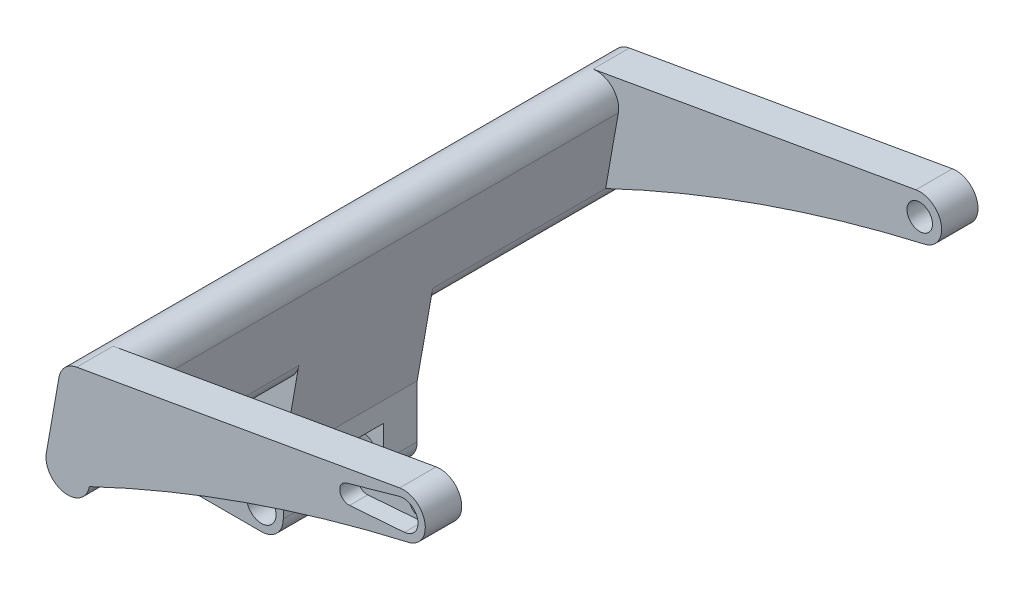
from build123d import *

# Parameters (mm, degrees)
SKETCH1_R               = 4.025
BOSS_EXTRUDE2_DEPTH     = 36.76
RIDE_SIDE_EXTRUDE_DEPTH = 57.47
LEFT_SIDE_EXTRUDE_DEPTH = 57.47
RIGHT_ARM_EXTRUDE_DEPTH = 10
SERVO_ARM_CUT_DEPTH     = 5
SKETCH18_R              = 3.5
SERVO_HOLE_DEPTH        = 152.7
SKETCH4_R               = 4.025
CUT_EXTRUDE2_DEPTH      = 18.38
SKETCH19_W              = 18.38
SKETCH19_H              = 9
CUT_EXTRUDE3_DEPTH      = 58.64


with BuildPart() as part:
    # Sketch1 → Boss-Extrude2 (new body)
    with BuildSketch(Plane.XY):
        with BuildLine():
            ThreePointArc((16.713283102, 15.01433341), (9.494630573, 8.397245558), (0, 6))
            ThreePointArc((0, 6), (-6, 0), (0, -6))
            Line((0, -6), (45.64, -6))
            ThreePointArc((45.64, -6), (49.882640687, -4.242640687), (51.64, 0))
            Line((51.64, 0), (51.64, 14.475068019))
            Line((51.64, 14.475068019), (59.363014513, 58.27445982))
            ThreePointArc((59.363014513, 58.27445982), (54.496057061, 65.225195404), (47.545321477, 60.358237952))
            Line((47.545321477, 60.358237952), (43.136706696, 35.355741095))
            ThreePointArc((43.136706696, 35.355741095), (36.080788508, 23.1345323), (22.82, 18.308))
            ThreePointArc((22.82, 18.308), (19.350841929, 17.432091905), (16.713283102, 15.01433341))
        make_face()
        Circle(SKETCH1_R, mode=Mode.SUBTRACT)
        with Locations((45.64, 0)):
            Circle(SKETCH1_R, mode=Mode.SUBTRACT)
        with Locations((22.82, 11)):
            Circle(SKETCH1_R, mode=Mode.SUBTRACT)
    extrude(amount=BOSS_EXTRUDE2_DEPTH)

    # Sketch5 → Ride-Side-Extrude (add)
    with BuildSketch(Plane.XY.offset(36.76)):
        with BuildLine():
            Line((55.89005096, 38.578304759), (59.363014513, 58.27445982))
            ThreePointArc((59.363014513, 58.27445982), (54.496057061, 65.225195404), (47.545321477, 60.358237952))
            Line((47.545321477, 60.358237952), (44.072357924, 40.662082891))
            ThreePointArc((44.072357924, 40.662082891), (48.939315376, 33.711347307), (55.89005096, 38.578304759))
        make_face()
    extrude(amount=RIDE_SIDE_EXTRUDE_DEPTH)

    # Sketch7 → Left-Side-Extrude (add)
    with BuildSketch(Plane(origin=(0, 0, 0), x_dir=(-1, 0, 0), z_dir=(0, 0, -1))):
        with BuildLine():
            Line((-44.072357924, 40.662082891), (-47.545321477, 60.358237952))
            ThreePointArc((-47.545321477, 60.358237952), (-54.496057061, 65.225195404), (-59.363014513, 58.27445982))
            Line((-59.363014513, 58.27445982), (-55.89005096, 38.578304759))
            ThreePointArc((-55.89005096, 38.578304759), (-48.939315376, 33.711347307), (-44.072357924, 40.662082891))
        make_face()
    extrude(amount=LEFT_SIDE_EXTRUDE_DEPTH)

    # Sketch16 → Right-Arm-Extrude (add)
    with BuildSketch(Plane.XY.offset(94.23)):
        with BuildLine():
            Line((141.0449767, 80.853531394), (52.412278929, 65.225195404))
            ThreePointArc((52.412278929, 65.225195404), (57.696808682, 63.558989573), (59.363014513, 58.27445982))
            Line((59.363014513, 58.27445982), (58.633475935, 54.137040945))
            Line((58.633475935, 54.137040945), (143.128754832, 69.035838357))
            ThreePointArc((143.128754832, 69.035838357), (147.995712284, 75.986573942), (141.0449767, 80.853531394))
        make_face()
        with BuildLine():
            ThreePointArc((55.89005096, 38.578304759), (98.679190662, 56.18502639), (143.128754832, 69.035838357))
            Line((143.128754832, 69.035838357), (58.633475935, 54.137040945))
            Line((58.633475935, 54.137040945), (55.89005096, 38.578304759))
        make_face()
    right_arm_extrude = extrude(amount=-RIGHT_ARM_EXTRUDE_DEPTH)

    # Sketch17 → Servo-Arm-Cut (cut)
    with BuildSketch(Plane.XY.offset(94.23)):
        with BuildLine():
            Line((141.006923599, 78.796142381), (126.442824066, 74.712393516))
            ThreePointArc((126.442824066, 74.712393516), (124.655768538, 71.871112131), (127.306826897, 69.812389968))
            Line((127.306826897, 69.812389968), (142.389328129, 70.956136704))
            ThreePointArc((142.389328129, 70.956136704), (146.026096778, 75.639277586), (141.006923599, 78.796142381))
        make_face()
    servo_arm_cut = extrude(amount=-SERVO_ARM_CUT_DEPTH, mode=Mode.SUBTRACT)

    # Sketch18 → Servo-hole (cut, through all)
    with BuildSketch(Plane.XY.offset(94.23)):
        with Locations((142.086865766, 74.944684876)):
            Circle(SKETCH18_R)
    servo_hole = extrude(amount=-SERVO_HOLE_DEPTH, mode=Mode.SUBTRACT)

    # Sketch4 → Cut-Extrude2 (cut)
    with BuildSketch(Plane(origin=(0, 0, 9.19), x_dir=(-1, 0, 0), z_dir=(0, 0, -1))):
        with BuildLine():
            Line((-45.64, -6), (0, -6))
            ThreePointArc((0, -6), (6, 0), (0, 6))
            ThreePointArc((0, 6), (-9.494630573, 8.397245558), (-16.713283102, 15.01433341))
            ThreePointArc((-16.713283102, 15.01433341), (-22.82, 18.308), (-28.926716898, 15.01433341))
            ThreePointArc((-28.926716898, 15.01433341), (-36.145369427, 8.397245558), (-45.64, 6))
            ThreePointArc((-45.64, 6), (-51.64, 0), (-45.64, -6))
        make_face()
        with Locations((-45.64, 0)):
            Circle(SKETCH4_R, mode=Mode.SUBTRACT)
        Circle(SKETCH4_R, mode=Mode.SUBTRACT)
        with Locations((-22.82, 11)):
            Circle(SKETCH4_R, mode=Mode.SUBTRACT)
    extrude(amount=-CUT_EXTRUDE2_DEPTH, mode=Mode.SUBTRACT)

    # Sketch19 → Cut-Extrude3 (cut, through all)
    with BuildSketch(Plane(origin=(51.64, 0, 0), x_dir=(0, 0, -1), z_dir=(1, 0, 0))):
        with Locations((-18.38, 4.5)):
            Rectangle(SKETCH19_W, SKETCH19_H)
    extrude(amount=-CUT_EXTRUDE3_DEPTH, mode=Mode.SUBTRACT)

    # Left-Arm Extrude: Right-Arm-Extrude, Servo-Arm-Cut, Servo-hole across plane
    add(right_arm_extrude.mirror(Plane(origin=(0, 0, 18.38), x_dir=(1, 0, 0), z_dir=(0, 0, -1))))
    add(servo_arm_cut.mirror(Plane(origin=(0, 0, 18.38), x_dir=(1, 0, 0), z_dir=(0, 0, -1))), mode=Mode.SUBTRACT)
    add(servo_hole.mirror(Plane(origin=(0, 0, 18.38), x_dir=(1, 0, 0), z_dir=(0, 0, -1))), mode=Mode.SUBTRACT)


solid = part.part
